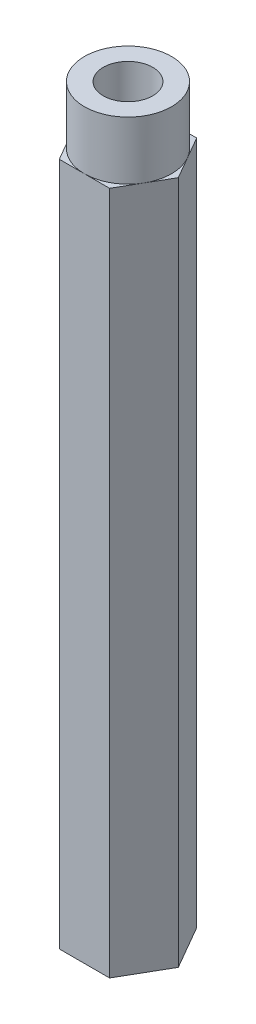
from build123d import *

# Parameters (mm, degrees)
BOSS_EXTRUDE1_DEPTH = 18.6944
SKETCH2_R           = 2.38125
BOSS_EXTRUDE2_DEPTH = 3.175
SKETCH3_R           = 1.35255
CUT_EXTRUDE1_DEPTH  = 6.35


with BuildPart() as part:
    # Sketch1 → Boss-Extrude1 (new body, symmetric)
    with BuildSketch(Plane(origin=(0, 0, 0), x_dir=(1, 0, 0), z_dir=(0, 1, 0))):
        Polygon((1.374815329, -2.38125), (2.749630657, 0), (1.374815329, 2.38125), (-1.374815329, 2.38125), (-2.749630657, 0), (-1.374815329, -2.38125), align=None)
    extrude(amount=BOSS_EXTRUDE1_DEPTH, both=True)

    # Sketch2 → Boss-Extrude2 (add)
    with BuildSketch(Plane(origin=(0, 18.6944, 0), x_dir=(1, 0, 0), z_dir=(0, 1, 0))):
        Circle(SKETCH2_R)
    extrude(amount=BOSS_EXTRUDE2_DEPTH)

    # Sketch3 → Cut-Extrude1 (cut)
    with BuildSketch(Plane(origin=(0, 21.8694, 0), x_dir=(1, 0, 0), z_dir=(0, 1, 0))):
        Circle(SKETCH3_R)
    extrude(amount=-CUT_EXTRUDE1_DEPTH, mode=Mode.SUBTRACT)


solid = part.part
